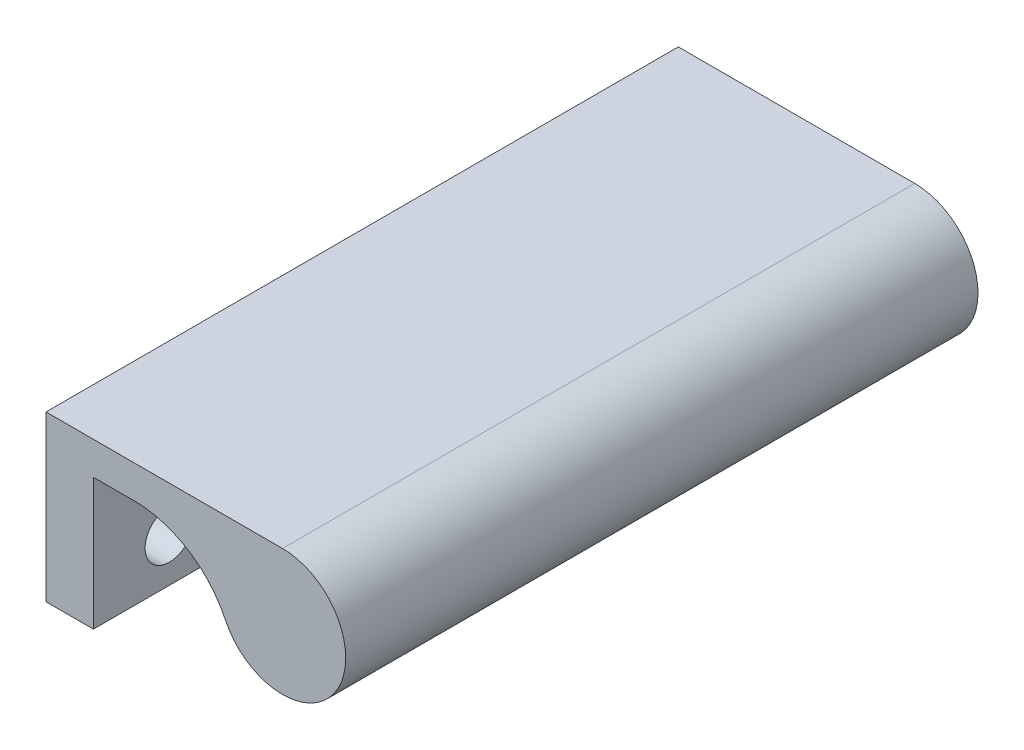
from build123d import *

# Parameters (mm, degrees)
SKETCH1_W        = 16.51
SKETCH1_H        = 63.5
SKETCH1_R        = 2.432856576
EXTRUSION1_DEPTH = 4.7625
SKETCH2_W        = 63.5
SKETCH2_H        = 3.302
EXTRUSION2_DEPTH = 1.016
EXTRUSION3_DEPTH = 63.5


with BuildPart() as part:
    # Sketch1 → Extrusion1 (new body)
    with BuildSketch(Plane.YZ):
        with Locations((8.255, -31.75)):
            Rectangle(SKETCH1_W, SKETCH1_H)
        with Locations((4.445, -55.61076)):
            Circle(SKETCH1_R, mode=Mode.SUBTRACT)
        with Locations((4.445, -47.6123)):
            Circle(SKETCH1_R, mode=Mode.SUBTRACT)
        with Locations((4.445, -39.61384)):
            Circle(SKETCH1_R, mode=Mode.SUBTRACT)
        with Locations((4.445, -31.61538)):
            Circle(SKETCH1_R, mode=Mode.SUBTRACT)
        with Locations((4.445, -23.61692)):
            Circle(SKETCH1_R, mode=Mode.SUBTRACT)
        with Locations((4.445, -15.61846)):
            Circle(SKETCH1_R, mode=Mode.SUBTRACT)
        with Locations((4.445, -7.62)):
            Circle(SKETCH1_R, mode=Mode.SUBTRACT)
    extrude(amount=EXTRUSION1_DEPTH)

    # Sketch2 → Extrusion2 (add)
    with BuildSketch(Plane(origin=(4.7625, 0, 0), x_dir=(0, 0, -1), z_dir=(1, 0, 0))):
        with Locations((31.75, 14.859)):
            Rectangle(SKETCH2_W, SKETCH2_H)
    extrude(amount=EXTRUSION2_DEPTH)

    # Sketch3 → Extrusion3 (add)
    with BuildSketch(Plane.XY):
        with BuildLine():
            Line((23.749, 16.51), (5.7785, 16.51))
            Line((5.7785, 16.51), (5.7785, 13.208))
            Line((5.7785, 13.208), (8.849350474, 13.208))
            ThreePointArc((8.849350474, 13.208), (14.269645101, 11.641369895), (18.018365567, 7.424615385))
            ThreePointArc((18.018365567, 7.424615385), (29.119856184, 6.772315858), (23.749, 16.51))
        make_face()
    extrude(amount=-EXTRUSION3_DEPTH)


solid = part.part
